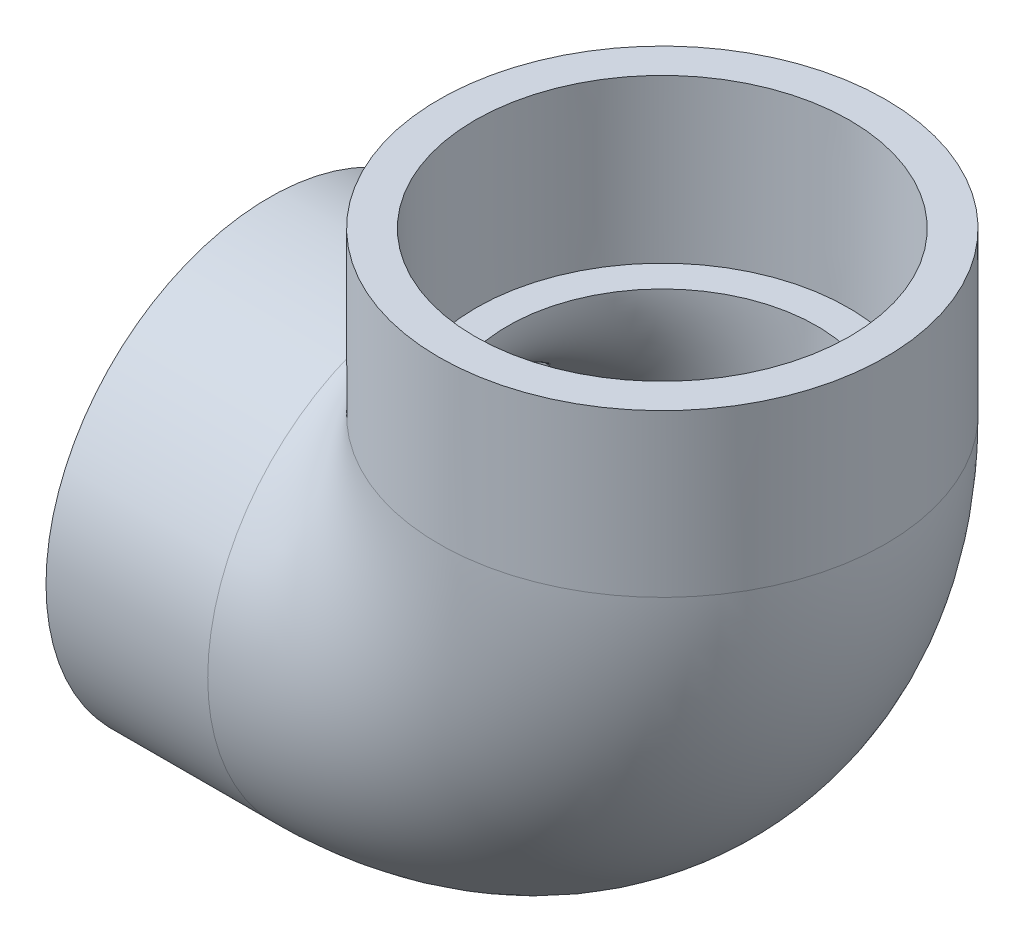
from build123d import *

# Parameters (mm, degrees)
SKETCH3_R   = 53.213
SKETCH3_R_2 = 36.83


with BuildPart() as part:
    # Sketch1 → Revolve1 (revolve)
    with BuildSketch(Plane.XY):
        Polygon((-93.6625, -53.213), (-55.118, -53.213), (-55.118, -44.3484), (-93.6625, -44.6532), align=None)
    revolve(axis=Axis((-93.6625, 0, 0), (1, 0, 0)))



with BuildPart() as body_2:
    # Sketch2 → Revolve2 (revolve)
    with BuildSketch(Plane.XY):
        Polygon((44.6532, 93.6625), (44.3484, 55.118), (53.213, 55.118), (53.213, 93.6625), align=None)
    revolve(axis=Axis((0, 0, 0), (0, 1, 0)))


with BuildPart() as part_1:
    add(part.part)

    add(body_2.part)  # Sweep1 merges body 2
    # Sweep1: sweep along a path in Sketch4
    with BuildLine(Plane.XY) as sweep1_path:
        ThreePointArc((-55.118, 0), (-16.143688435, 16.143688435), (0, 55.118))
    # Sketch3 → Sweep1 (sweep)
    with BuildSketch(Plane(origin=(-55.118, 0, 0), x_dir=(0, 0, -1), z_dir=(1, 0, 0))):
        Circle(SKETCH3_R)
        Circle(SKETCH3_R_2, mode=Mode.SUBTRACT)
    sweep(path=sweep1_path.line)


solid = part_1.part
